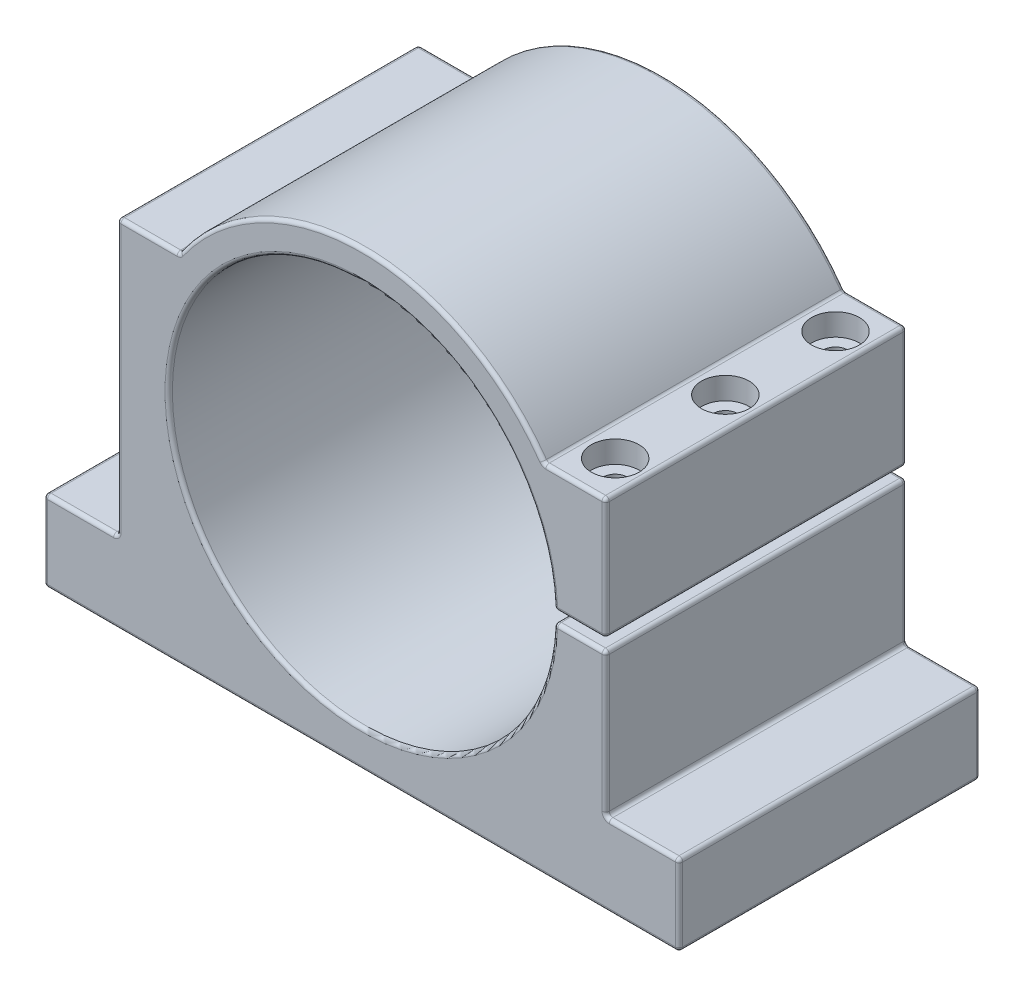
from build123d import *

# Parameters (mm, degrees)
EXTRUDE_1_DEPTH     = 41
SKETCH_2_R          = 6.5
CUT_EXTRUDE_1_DEPTH = 6
SKETCH_3_R          = 3.25
CUT_EXTRUDE_2_DEPTH = 36
SKETCH_4_R          = 2.35
CUT_EXTRUDE_3_DEPTH = 30
FILLET_1_R          = 1


with BuildPart() as part:
    # Эскиз1 → Бобышка-Вытянуть1 (new body, symmetric)
    with BuildSketch(Plane.XY):
        with BuildLine():
            Line((-86.5, -62.5), (86.5, -62.5))
            Line((86.5, -62.5), (86.5, -40.5))
            Line((86.5, -40.5), (66.5, -40.5))
            Line((66.5, -40.5), (66.5, -1.5))
            Line((66.5, -1.5), (60.4814021, -1.5))
            ThreePointArc((60.4814021, -1.5), (-18.790011681, -57.508133868), (-49.699094559, 34.5))
            Line((-49.699094559, 34.5), (-66.5, 34.5))
            Line((-66.5, 34.5), (-66.5, -40.5))
            Line((-66.5, -40.5), (-86.5, -40.5))
            Line((-86.5, -40.5), (-86.5, -62.5))
        make_face()
        with BuildLine():
            ThreePointArc((-49.699094559, 34.5), (-18.790011681, -57.508133868), (60.4814021, -1.5))
            Line((60.4814021, -1.5), (52.478567054, -1.5))
            ThreePointArc((52.478567054, -1.5), (-19.121721569, -48.893862235), (-39.572717875, 34.5))
            Line((-39.572717875, 34.5), (-49.699094559, 34.5))
        make_face()
        with BuildLine():
            ThreePointArc((49.699094559, 34.5), (0, 60.5), (-49.699094559, 34.5))
            Line((-49.699094559, 34.5), (-39.572717875, 34.5))
            ThreePointArc((-39.572717875, 34.5), (0, 52.5), (39.572717875, 34.5))
            Line((39.572717875, 34.5), (49.699094559, 34.5))
        make_face()
        with BuildLine():
            Line((52.478567054, 1.5), (60.4814021, 1.5))
            ThreePointArc((60.4814021, 1.5), (57.508133868, 18.790011681), (49.699094559, 34.5))
            Line((49.699094559, 34.5), (39.572717875, 34.5))
            ThreePointArc((39.572717875, 34.5), (48.893862235, 19.121721569), (52.478567054, 1.5))
        make_face()
        with BuildLine():
            Line((60.4814021, 1.5), (66.5, 1.5))
            Line((66.5, 1.5), (66.5, 34.5))
            Line((66.5, 34.5), (49.699094559, 34.5))
            ThreePointArc((49.699094559, 34.5), (57.508133868, 18.790011681), (60.4814021, 1.5))
        make_face()
    extrude(amount=EXTRUDE_1_DEPTH, both=True)

    # Эскиз2 → Вырез-Вытянуть1 (cut)
    with BuildSketch(Plane(origin=(0, 34.5, 0), x_dir=(1, 0, 0), z_dir=(0, 1, 0))):
        with Locations((58.09954728, 30)):
            Circle(SKETCH_2_R)
        with Locations((58.09954728, 0)):
            Circle(SKETCH_2_R)
        with Locations((58.09954728, -30)):
            Circle(SKETCH_2_R)
    extrude(amount=-CUT_EXTRUDE_1_DEPTH, mode=Mode.SUBTRACT)

    # Эскиз3 → Вырез-Вытянуть2 (cut)
    with BuildSketch(Plane(origin=(0, 34.5, 0), x_dir=(1, 0, 0), z_dir=(0, 1, 0))):
        with Locations((58.09954728, 30)):
            Circle(SKETCH_3_R)
        with Locations((58.09954728, 0)):
            Circle(SKETCH_3_R)
        with Locations((58.09954728, -30)):
            Circle(SKETCH_3_R)
    extrude(amount=-CUT_EXTRUDE_2_DEPTH, mode=Mode.SUBTRACT)

    # Эскиз4 → Вырез-Вытянуть3 (cut)
    with BuildSketch(Plane(origin=(0, -1.5, 0), x_dir=(1, 0, 0), z_dir=(0, 1, 0))):
        with Locations((58.09954728, 30)):
            Circle(SKETCH_4_R)
        with Locations((58.09954728, 0)):
            Circle(SKETCH_4_R)
        with Locations((58.09954728, -30)):
            Circle(SKETCH_4_R)
    extrude(amount=-CUT_EXTRUDE_3_DEPTH, mode=Mode.SUBTRACT)

    # Скругление1
    fillet_1_edges = [part.edges().sort_by_distance(p)[0] for p in [
        (66.5, -21, -41),
        (59.489283527, 1.5, 41),
        (76.5, -40.5, -41),
        (86.5, -51.5, -41),
        (0, -62.5, -41),
        (-86.5, -51.5, -41),
        (-76.5, -40.5, -41),
        (-66.5, -3, -41),
        (-58.09954728, 34.5, -41),
        (0, 60.5, -41),
        (58.09954728, 34.5, -41),
        (66.5, 18, -41),
        (66.5, 18, 41),
        (59.489283527, 1.5, -41),
        (-52.5, 0, -41),
        (59.489283527, -1.5, -41),
        (58.09954728, 34.5, 41),
        (66.5, -1.5, 0),
        (66.5, -40.5, 0),
        (86.5, -40.5, 0),
        (86.5, -62.5, 0),
        (-86.5, -62.5, 0),
        (-86.5, -40.5, 0),
        (-66.5, -40.5, 0),
        (-66.5, 34.5, 0),
        (-49.699094559, 34.5, 0),
        (49.699094559, 34.5, 0),
        (66.5, 34.5, 0),
        (66.5, 1.5, 0),
        (52.478567054, 1.5, 0),
        (52.478567054, -1.5, 0),
        (0, 60.5, 41),
        (-58.09954728, 34.5, 41),
        (-66.5, -3, 41),
        (59.489283527, -1.5, 41),
        (-76.5, -40.5, 41),
        (-86.5, -51.5, 41),
        (0, -62.5, 41),
        (86.5, -51.5, 41),
        (76.5, -40.5, 41),
        (66.5, -21, 41),
        (-52.5, 0, 41),
    ]]
    fillet(fillet_1_edges, radius=FILLET_1_R)


solid = part.part
